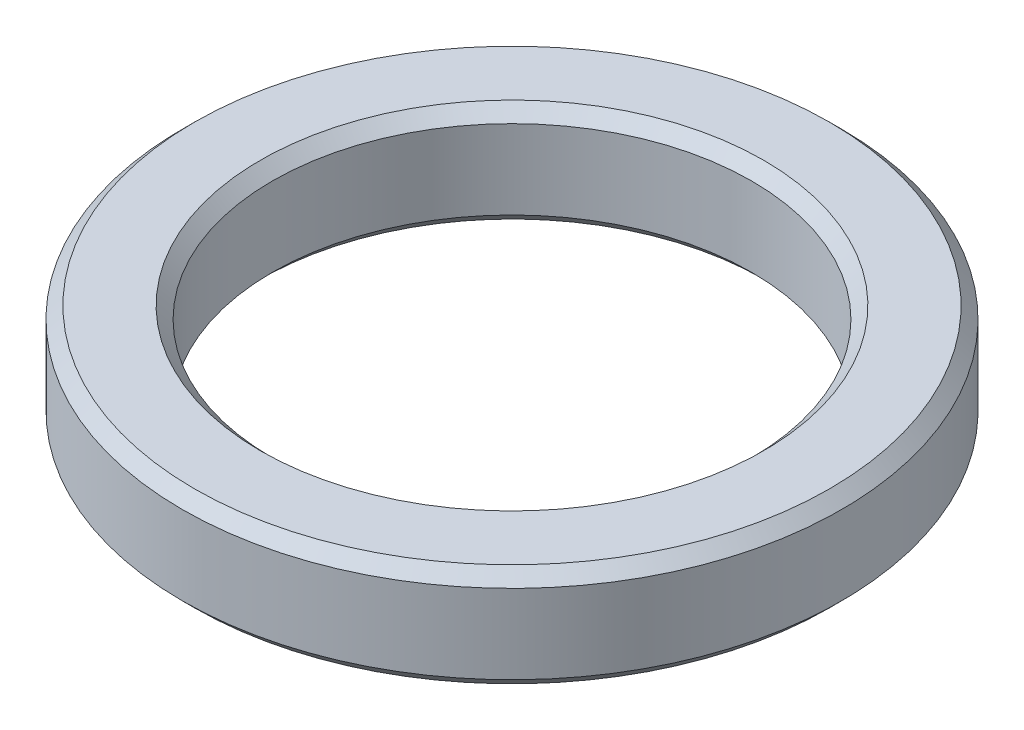
from build123d import *

# Parameters (mm, degrees)
SKIZZE1_R                       = 2.75
SKIZZE1_R_2                     = 2
AUFSATZ_LINEAR_AUSTRAGEN1_DEPTH = 0.86
FASE1_SIZE                      = 0.1


with BuildPart() as part:
    # Skizze1 → Aufsatz-Linear austragen1 (new body)
    with BuildSketch(Plane(origin=(0, 0, 0), x_dir=(1, 0, 0), z_dir=(0, 1, 0))):
        Circle(SKIZZE1_R)
        Circle(SKIZZE1_R_2, mode=Mode.SUBTRACT)
    extrude(amount=AUFSATZ_LINEAR_AUSTRAGEN1_DEPTH)

    # Fase1
    fase1_edges = [part.edges().sort_by_distance(p)[0] for p in [
        (-2.75, 0, 0),
        (-2.75, 0.86, 0),
        (-2, 0, 0),
        (-2, 0.86, 0),
    ]]
    chamfer(fase1_edges, length=FASE1_SIZE)


solid = part.part
